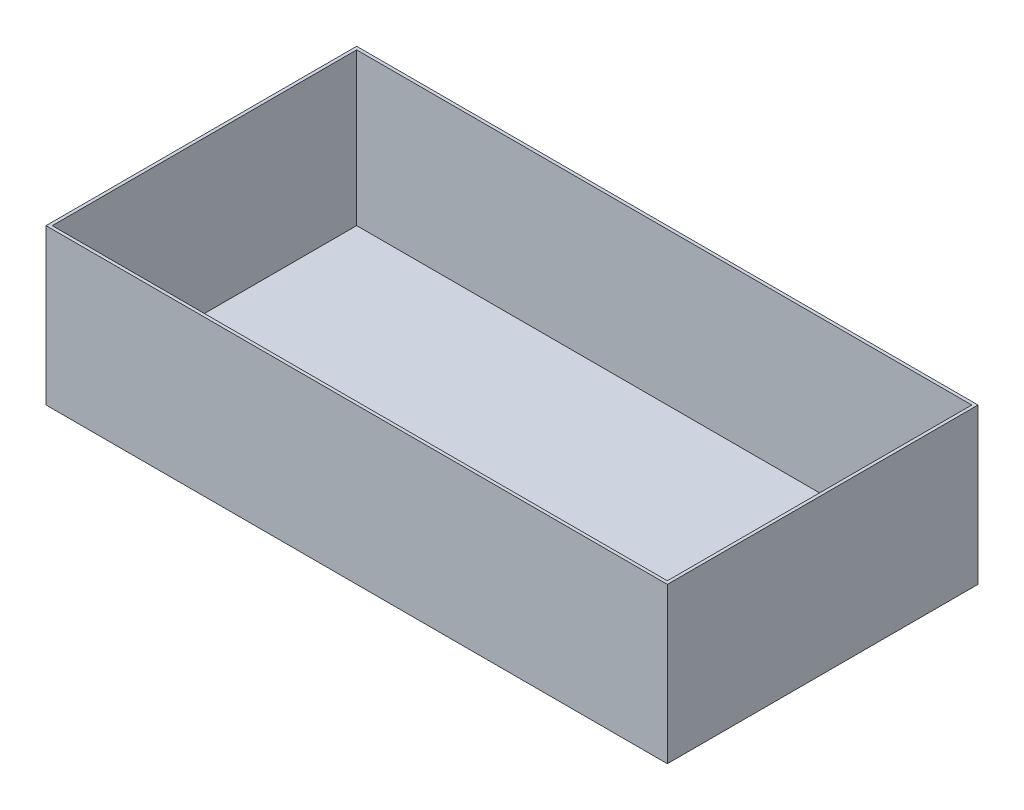
from build123d import *

# Parameters (mm, degrees)
SKETCH5_W           = 200
SKETCH5_H           = 100
BOSS_EXTRUDE2_DEPTH = 50
SKETCH6_W           = 198
SKETCH6_H           = 98
CUT_EXTRUDE2_DEPTH  = 49


with BuildPart() as part:
    # Sketch5 → Boss-Extrude2 (new body)
    with BuildSketch(Plane(origin=(0, 0, 0), x_dir=(1, 0, 0), z_dir=(0, 1, 0))):
        Rectangle(SKETCH5_W, SKETCH5_H)
    extrude(amount=BOSS_EXTRUDE2_DEPTH)

    # Sketch6 → Cut-Extrude2 (cut)
    with BuildSketch(Plane(origin=(0, 50, 0), x_dir=(1, 0, 0), z_dir=(0, 1, 0))):
        Rectangle(SKETCH6_W, SKETCH6_H)
    extrude(amount=-CUT_EXTRUDE2_DEPTH, mode=Mode.SUBTRACT)


solid = part.part
